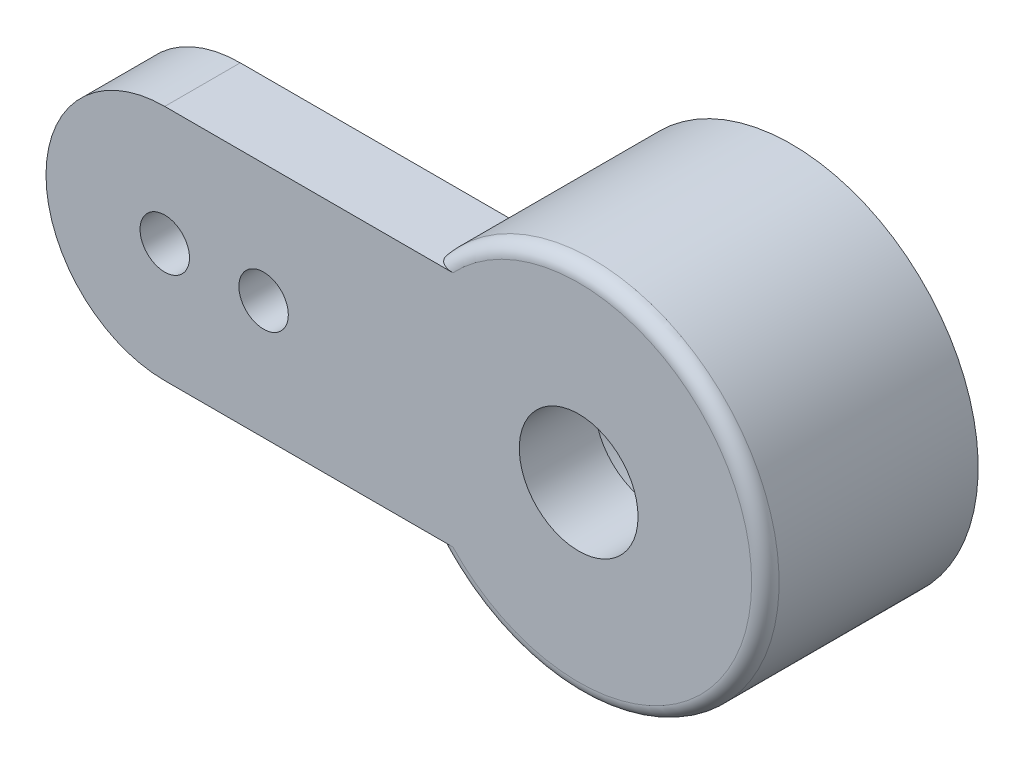
from build123d import *

# Parameters (mm, degrees)
SKETCH_1_R      = 0.36
SKETCH_1_R_2    = 0.865
EXTRUDE_1_DEPTH = 1.1
EXTRUDE_START   = 2
SKETCH_2_R      = 2.7200000000000006
SKETCH_2_R_2    = 1.95
EXTRUDE_2_DEPTH = 2
FILLET_1_R      = 0.2


with BuildPart() as part:
    # 草图1 → 凸台-拉伸1 (new body)
    # profile 1 of 3: a face of its own
    with BuildSketch(Plane.XY):
        with BuildLine():
            Line((-2.0989282979654043, 1.7299999999999998), (-6.029999999999999, 1.7299999999999998))
            ThreePointArc((-6.029999999999999, 1.7299999999999995), (-7.759999999999999, -1.2e-16), (-6.029999999999999, -1.73))
            Line((-6.029999999999999, -1.7299999999999998), (-2.098928297965404, -1.7299999999999998))
            ThreePointArc((-2.0989282979654083, -1.7300000000000109), (-2.7200000000000006, 3.3e-16), (-2.098928297965408, 1.7300000000000115))
        make_face()
        with Locations((-6.029999999999999, 0)):
            Circle(SKETCH_1_R, mode=Mode.SUBTRACT)
        with Locations((-4.590000000000001, 0)):
            Circle(SKETCH_1_R, mode=Mode.SUBTRACT)
    # profile 2 of 3: a face of its own
    with BuildSketch(Plane.XY):
        with BuildLine():
            Line((0, 1.7299999999999998), (-2.0989282979654043, 1.7299999999999998))
            ThreePointArc((-2.098928297965408, 1.7300000000000115), (-2.7200000000000006, 3.3e-16), (-2.0989282979654083, -1.7300000000000109))
            Line((-2.098928297965404, -1.7299999999999998), (0, -1.7299999999999998))
            ThreePointArc((0, -1.7299999999999995), (1.7299999999999998, 1e-17), (2.1e-16, 1.73))
        make_face()
        Circle(SKETCH_1_R_2, mode=Mode.SUBTRACT)
    # profile 3 of 3: a face of its own
    with BuildSketch(Plane.XY):
        with BuildLine():
            ThreePointArc((2.7200000000000006, 0), (0.9190525092545292, 2.5600278289958016), (-2.098928297965408, 1.7300000000000115))
            Line((-2.0989282979654043, 1.7299999999999998), (0, 1.7299999999999998))
            ThreePointArc((2.1e-16, 1.73), (1.7299999999999998, 1e-17), (0, -1.7299999999999995))
            Line((0, -1.7299999999999998), (-2.098928297965404, -1.7299999999999998))
            ThreePointArc((-2.0989282979654083, -1.7300000000000109), (0.9190525092545296, -2.5600278289958016), (2.7200000000000006, -6.7e-16))
        make_face()
    extrude(amount=EXTRUDE_1_DEPTH)

    # 草图2 → 凸台-拉伸2 (add)
    with BuildSketch(Plane(origin=(0, 0, 0), x_dir=(-1, 0, 0), z_dir=(0, 0, -1)).offset(EXTRUDE_START)):
        Circle(SKETCH_2_R)
        Circle(SKETCH_2_R_2, mode=Mode.SUBTRACT)
    extrude(amount=-EXTRUDE_2_DEPTH)

    # 圆角1
    fillet_1_edges = [part.edges().sort_by_distance(p)[0] for p in [
        (2.7200000000000015, 1e-15, 1.1),
    ]]
    fillet(fillet_1_edges, radius=FILLET_1_R)


solid = part.part
